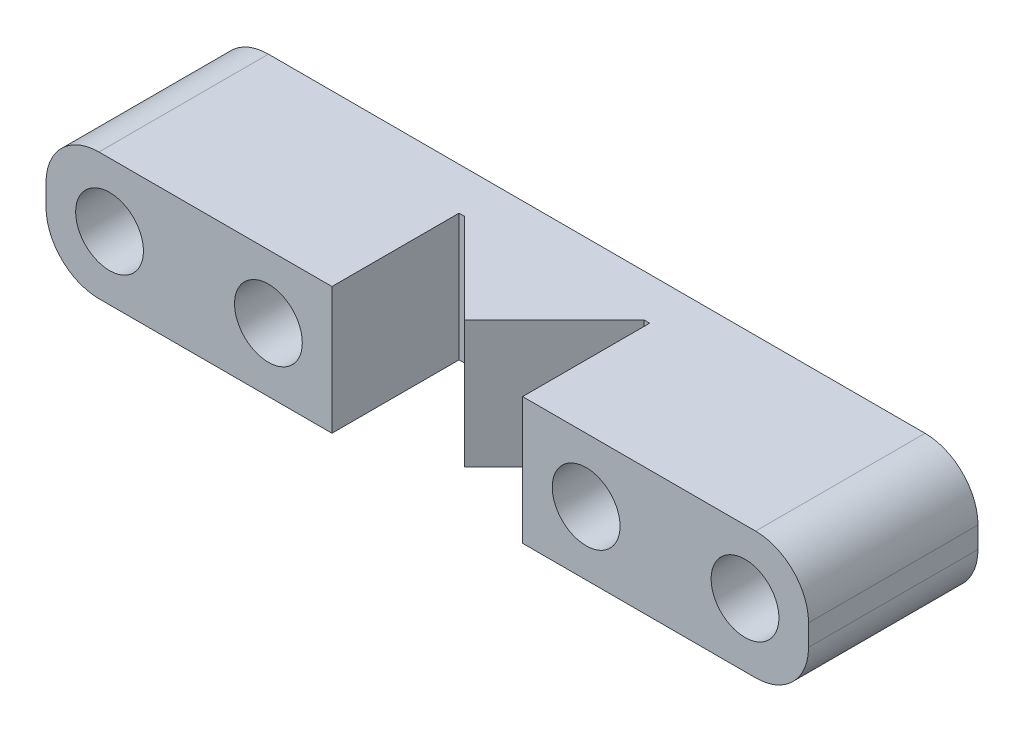
from build123d import *

# Parameters (mm, degrees)
SKETCH1_R           = 1.6
BOSS_EXTRUDE1_DEPTH = 8
SKETCH2_W           = 9
SKETCH2_H           = 8.199711987
CUT_EXTRUDE1_DEPTH  = 8
BOSS_EXTRUDE2_DEPTH = 6
SKETCH4_R           = 1.6
BOSS_EXTRUDE3_DEPTH = 8


with BuildPart() as part:
    # Sketch1 → Boss-Extrude1 (new body)
    with BuildSketch(Plane.XY):
        with BuildLine():
            Line((-0.5, 3), (15.5, 3))
            ThreePointArc((15.5, 3), (17.267766953, 2.267766953), (18, 0.5))
            Line((18, 0.5), (18, -0.5))
            ThreePointArc((18, -0.5), (17.267766953, -2.267766953), (15.5, -3))
            Line((15.5, -3), (-0.5, -3))
            ThreePointArc((-0.5, -3), (-2.267766953, -2.267766953), (-3, -0.5))
            Line((-3, -0.5), (-3, 0.5))
            ThreePointArc((-3, 0.5), (-2.267766953, 2.267766953), (-0.5, 3))
        make_face()
        Circle(SKETCH1_R, mode=Mode.SUBTRACT)
        with Locations((15, 0)):
            Circle(SKETCH1_R, mode=Mode.SUBTRACT)
    extrude(amount=BOSS_EXTRUDE1_DEPTH)

    # Sketch2 → Cut-Extrude1 (cut)
    with BuildSketch(Plane.XZ.offset(3)):
        with Locations((7.5, 6.099855994)):
            Rectangle(SKETCH2_W, SKETCH2_H)
    extrude(amount=-CUT_EXTRUDE1_DEPTH, mode=Mode.SUBTRACT)

    # Sketch3 → Boss-Extrude2 (add)
    with BuildSketch(Plane.XZ.offset(3)):
        Polygon((3.257359313, 2), (7.5, 6.242640687), (11.742640687, 2), align=None)
    extrude(amount=-BOSS_EXTRUDE2_DEPTH)

    # Sketch4 → Boss-Extrude3 (add)
    with BuildSketch(Plane(origin=(0, 0, 0), x_dir=(-1, 0, 0), z_dir=(0, 0, -1))):
        with BuildLine():
            ThreePointArc((8, 3), (9.767766953, 2.267766953), (10.5, 0.5))
            Line((10.5, 0.5), (10.5, -0.5))
            ThreePointArc((10.5, -0.5), (9.767766953, -2.267766953), (8, -3))
            Line((8, -3), (0.5, -3))
            ThreePointArc((0.5, -3), (2.267766953, -2.267766953), (3, -0.5))
            Line((3, -0.5), (3, 0.5))
            ThreePointArc((3, 0.5), (2.267766953, 2.267766953), (0.5, 3))
            Line((0.5, 3), (8, 3))
        make_face()
        with Locations((7.5, 0)):
            Circle(SKETCH4_R, mode=Mode.SUBTRACT)
        with BuildLine():
            ThreePointArc((-23, -3), (-24.767766953, -2.267766953), (-25.5, -0.5))
            Line((-25.5, -0.5), (-25.5, 0.5))
            ThreePointArc((-25.5, 0.5), (-24.767766953, 2.267766953), (-23, 3))
            Line((-23, 3), (-15.5, 3))
            ThreePointArc((-15.5, 3), (-17.267766953, 2.267766953), (-18, 0.5))
            Line((-18, 0.5), (-18, -0.5))
            ThreePointArc((-18, -0.5), (-17.267766953, -2.267766953), (-15.5, -3))
            Line((-15.5, -3), (-23, -3))
        make_face()
        with Locations((-22.5, 0)):
            Circle(SKETCH4_R, mode=Mode.SUBTRACT)
    extrude(amount=-BOSS_EXTRUDE3_DEPTH)


solid = part.part
